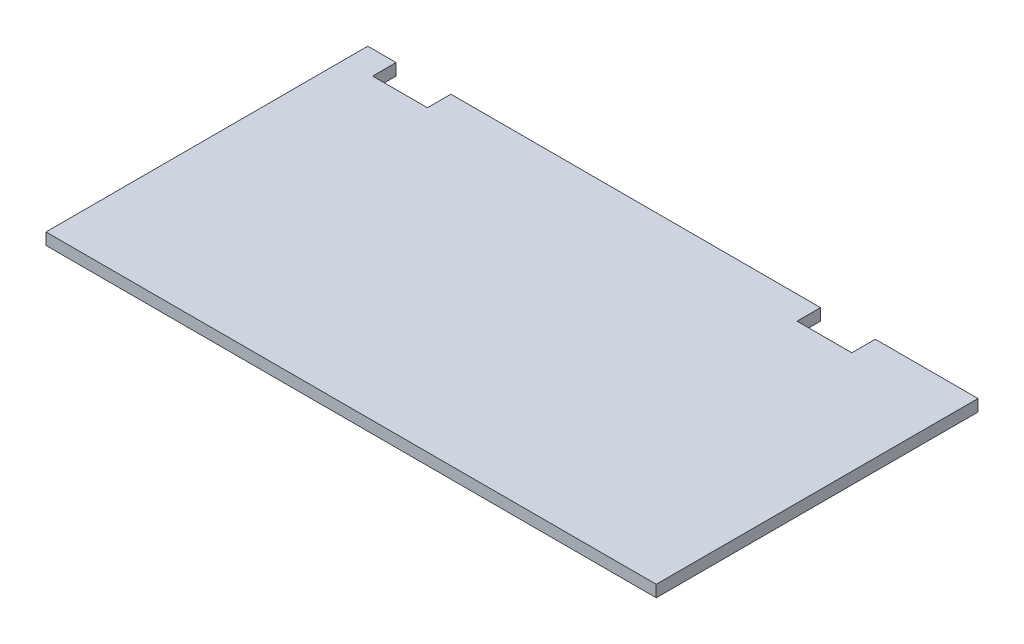
from build123d import *

# Parameters (mm, degrees)
SKETCH1_W           = 990.6
SKETCH1_H           = 522.2875
BOSS_EXTRUDE1_DEPTH = 19.05
SKETCH2_W           = 88.9
SKETCH2_H           = 38.1
CUT_EXTRUDE1_DEPTH  = 20.05


with BuildPart() as part:
    # Sketch1 → Boss-Extrude1 (new body)
    with BuildSketch(Plane(origin=(0, 0, 0), x_dir=(1, 0, 0), z_dir=(0, 1, 0))):
        with Locations((495.3, 261.14375)):
            Rectangle(SKETCH1_W, SKETCH1_H)
    extrude(amount=BOSS_EXTRUDE1_DEPTH)

    # Sketch2 → Cut-Extrude1 (cut, through all)
    with BuildSketch(Plane(origin=(0, 19.05, 0), x_dir=(1, 0, 0), z_dir=(0, 1, 0))):
        with Locations((779.4625, 503.2375)):
            Rectangle(SKETCH2_W, SKETCH2_H)
        with Locations((90.4875, 503.2375)):
            Rectangle(SKETCH2_W, SKETCH2_H)
    extrude(amount=-CUT_EXTRUDE1_DEPTH, mode=Mode.SUBTRACT)


solid = part.part
